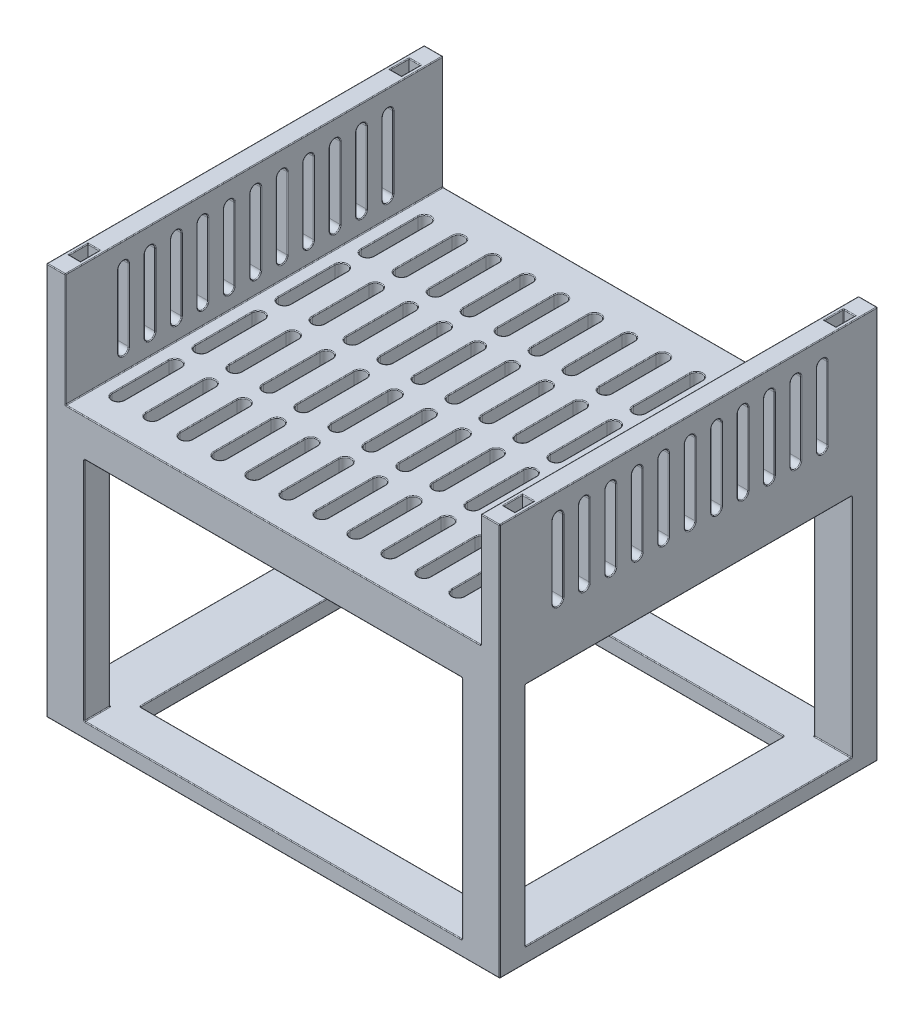
from build123d import *

# Parameters (mm, degrees)
ESBO_O1_W                 = 600
ESBO_O1_H                 = 500
RESSALTO_EXTRUS_O1_DEPTH  = 50
ESBO_O3_W                 = 25
ESBO_O3_H                 = 500
RESSALTO_EXTRUS_O2_DEPTH  = 150
CORTE_EXTRUS_O6_DEPTH     = 201
PADR_O_LINEAR1_COUNT      = 12
PADR_O_LINEAR1_PITCH      = 45
PADR_O_LINEAR1_COUNT_DIR2 = 4
PADR_O_LINEAR1_PITCH_DIR2 = 110
ESBO_O15_W                = 50
ESBO_O15_H                = 34
RESSALTO_EXTRUS_O4_DEPTH  = 300
ESBO_O16_W                = 600
ESBO_O16_H                = 500
ESBO_O16_W_2              = 460
ESBO_O16_H_2              = 392
RESSALTO_EXTRUS_O6_DEPTH  = 20
ESBO_O17_W                = 15
ESBO_O17_H                = 25
CORTE_EXTRUS_O7_DEPTH     = 60
CORTE_EXTRUS_O8_DEPTH     = 601
PADR_O_LINEAR2_COUNT      = 11
PADR_O_LINEAR2_PITCH      = 35
FILETE1_R                 = 1


with BuildPart() as part:
    # Esboço1 → Ressalto-extrusão1 (new body)
    with BuildSketch(Plane(origin=(0, 0, 0), x_dir=(1, 0, 0), z_dir=(0, 1, 0))):
        with Locations((300, 250)):
            Rectangle(ESBO_O1_W, ESBO_O1_H)
    extrude(amount=RESSALTO_EXTRUS_O1_DEPTH)

    # Esboço3 → Ressalto-extrusão2 (add)
    with BuildSketch(Plane(origin=(0, 50, 0), x_dir=(1, 0, 0), z_dir=(0, 1, 0))):
        with Locations((12.5, 250)):
            Rectangle(ESBO_O3_W, ESBO_O3_H)
        with Locations((587.5, 250)):
            Rectangle(ESBO_O3_W, ESBO_O3_H)
    extrude(amount=RESSALTO_EXTRUS_O2_DEPTH)

    # Esboço13 → Corte-extrusão6 (cut, through all)
    with BuildSketch(Plane.XZ):
        with BuildLine():
            Line((58, -45), (58, -120))
            ThreePointArc((58, -120), (50, -128), (42, -120))
            Line((42, -120), (42, -45))
            ThreePointArc((42, -45), (50, -37), (58, -45))
        make_face()
    corte_extrus_o6 = extrude(amount=-CORTE_EXTRUS_O6_DEPTH, mode=Mode.SUBTRACT)

    # Padrão linear1: Corte-extrus_o6 12 × 4
    with Locations(*[(i * PADR_O_LINEAR1_PITCH, 0, -j * PADR_O_LINEAR1_PITCH_DIR2) for i in range(PADR_O_LINEAR1_COUNT) for j in range(PADR_O_LINEAR1_COUNT_DIR2) if (i, j) != (0, 0)]):
        add(corte_extrus_o6, mode=Mode.SUBTRACT)

    # Esboço15 → Ressalto-extrusão4 (add)
    with BuildSketch(Plane.XZ):
        with Locations((25, -17)):
            Rectangle(ESBO_O15_W, ESBO_O15_H)
        with Locations((575, -17)):
            Rectangle(ESBO_O15_W, ESBO_O15_H)
        with Locations((575, -483)):
            Rectangle(ESBO_O15_W, ESBO_O15_H)
        with Locations((25, -483)):
            Rectangle(ESBO_O15_W, ESBO_O15_H)
    extrude(amount=RESSALTO_EXTRUS_O4_DEPTH)

    # Esboço16 → Ressalto-extrusão6 (add)
    with BuildSketch(Plane.XZ.offset(300)):
        with Locations((300, -250)):
            Rectangle(ESBO_O16_W, ESBO_O16_H)
        with Locations((300, -250)):
            Rectangle(ESBO_O16_W_2, ESBO_O16_H_2, mode=Mode.SUBTRACT)
    extrude(amount=RESSALTO_EXTRUS_O6_DEPTH)

    # Esboço17 → Corte-extrusão7 (cut)
    with BuildSketch(Plane(origin=(0, 200, 0), x_dir=(1, 0, 0), z_dir=(0, 1, 0))):
        with Locations((12.5, 462.5)):
            Rectangle(ESBO_O17_W, ESBO_O17_H)
        with Locations((587.5, 462.5)):
            Rectangle(ESBO_O17_W, ESBO_O17_H)
        with Locations((587.5, 37.5)):
            Rectangle(ESBO_O17_W, ESBO_O17_H)
        with Locations((12.5, 37.5)):
            Rectangle(ESBO_O17_W, ESBO_O17_H)
    extrude(amount=-CORTE_EXTRUS_O7_DEPTH, mode=Mode.SUBTRACT)

    # Esboço18 → Corte-extrusão8 (cut, through all)
    with BuildSketch(Plane(origin=(600, 0, 0), x_dir=(0, 0, -1), z_dir=(1, 0, 0))):
        with BuildLine():
            Line((84, 170), (84, 75))
            ThreePointArc((84, 75), (77, 68), (70, 75))
            Line((70, 75), (70, 170))
            ThreePointArc((70, 170), (77, 177), (84, 170))
        make_face()
    corte_extrus_o8 = extrude(amount=-CORTE_EXTRUS_O8_DEPTH, mode=Mode.SUBTRACT)

    # Padrão linear2: Corte-extrusão8 ×11
    with Locations(*[(0, 0, -i * PADR_O_LINEAR2_PITCH) for i in range(1, PADR_O_LINEAR2_COUNT)]):
        add(corte_extrus_o8, mode=Mode.SUBTRACT)

    # Filete1
    filete1_edges = [part.edges().sort_by_distance(p)[0] for p in [
        (320, 0, -37),
        (328, 0, -82.5),
        (320, 0, -128),
        (312, 0, -82.5),
        (320, 50, -37),
        (312, 50, -82.5),
        (320, 50, -128),
        (328, 50, -82.5),
        (365, 0, -37),
        (373, 0, -82.5),
        (365, 0, -128),
        (357, 0, -82.5),
        (365, 50, -37),
        (357, 50, -82.5),
        (365, 50, -128),
        (373, 50, -82.5),
        (410, 0, -37),
        (418, 0, -82.5),
        (410, 0, -128),
        (402, 0, -82.5),
        (410, 50, -37),
        (402, 50, -82.5),
        (410, 50, -128),
        (418, 50, -82.5),
        (455, 0, -37),
        (463, 0, -82.5),
        (455, 0, -128),
        (447, 0, -82.5),
        (455, 50, -37),
        (447, 50, -82.5),
        (455, 50, -128),
        (463, 50, -82.5),
        (500, 0, -37),
        (508, 0, -82.5),
        (300, 50, 0),
        (500, 0, -128),
        (492, 0, -82.5),
        (500, 50, -37),
        (492, 50, -82.5),
        (500, 50, -128),
        (508, 50, -82.5),
        (545, 0, -37),
        (553, 0, -82.5),
        (545, 0, -128),
        (537, 0, -82.5),
        (545, 50, -37),
        (537, 50, -82.5),
        (545, 50, -128),
        (553, 50, -82.5),
        (50, 0, -147),
        (58, 0, -192.5),
        (50, 0, -238),
        (42, 0, -192.5),
        (50, 50, -147),
        (42, 50, -192.5),
        (50, 50, -238),
        (58, 50, -192.5),
        (25, 50, -250),
        (25, 125, 0),
        (95, 0, -147),
        (103, 0, -192.5),
        (95, 0, -238),
        (87, 0, -192.5),
        (95, 50, -147),
        (87, 50, -192.5),
        (25, 125, -500),
        (95, 50, -238),
        (103, 50, -192.5),
        (0, 200, -250),
        (12.5, 200, 0),
        (140, 0, -147),
        (148, 0, -192.5),
        (140, 0, -238),
        (25, 200, -250),
        (132, 0, -192.5),
        (140, 50, -147),
        (132, 50, -192.5),
        (140, 50, -238),
        (148, 50, -192.5),
        (12.5, 200, -500),
        (185, 0, -147),
        (193, 0, -192.5),
        (185, 0, -238),
        (177, 0, -192.5),
        (185, 50, -147),
        (177, 50, -192.5),
        (185, 50, -238),
        (193, 50, -192.5),
        (230, 0, -147),
        (238, 0, -192.5),
        (230, 0, -238),
        (222, 0, -192.5),
        (230, 50, -147),
        (222, 50, -192.5),
        (230, 50, -238),
        (238, 50, -192.5),
        (275, 0, -147),
        (283, 0, -192.5),
        (275, 0, -238),
        (267, 0, -192.5),
        (275, 50, -147),
        (267, 50, -192.5),
        (275, 50, -238),
        (283, 50, -192.5),
        (320, 0, -147),
        (328, 0, -192.5),
        (320, 0, -238),
        (312, 0, -192.5),
        (320, 50, -147),
        (312, 50, -192.5),
        (320, 50, -238),
        (328, 50, -192.5),
        (365, 0, -147),
        (373, 0, -192.5),
        (365, 0, -238),
        (357, 0, -192.5),
        (365, 50, -147),
        (357, 50, -192.5),
        (365, 50, -238),
        (373, 50, -192.5),
        (410, 0, -147),
        (418, 0, -192.5),
        (410, 0, -238),
        (402, 0, -192.5),
        (410, 50, -147),
        (402, 50, -192.5),
        (410, 50, -238),
        (418, 50, -192.5),
        (455, 0, -147),
        (463, 0, -192.5),
        (455, 0, -238),
        (447, 0, -192.5),
        (455, 50, -147),
        (447, 50, -192.5),
        (455, 50, -238),
        (463, 50, -192.5),
        (500, 0, -147),
        (508, 0, -192.5),
        (500, 0, -238),
        (492, 0, -192.5),
        (500, 50, -147),
        (492, 50, -192.5),
        (500, 50, -238),
        (508, 50, -192.5),
        (545, 0, -147),
        (553, 0, -192.5),
        (545, 0, -238),
        (537, 0, -192.5),
        (545, 50, -147),
        (537, 50, -192.5),
        (545, 50, -238),
        (553, 50, -192.5),
        (300, 50, -500),
        (50, 0, -257),
        (58, 0, -302.5),
        (50, 0, -348),
        (42, 0, -302.5),
        (50, 50, -257),
        (42, 50, -302.5),
        (50, 50, -348),
        (58, 50, -302.5),
        (95, 0, -257),
        (103, 0, -302.5),
        (95, 0, -348),
        (87, 0, -302.5),
        (95, 50, -257),
        (87, 50, -302.5),
        (95, 50, -348),
        (103, 50, -302.5),
        (575, 50, -250),
        (140, 0, -257),
        (148, 0, -302.5),
        (140, 0, -348),
        (132, 0, -302.5),
        (575, 125, -500),
        (140, 50, -257),
        (132, 50, -302.5),
        (140, 50, -348),
        (148, 50, -302.5),
        (575, 125, 0),
        (600, 200, -250),
        (185, 0, -257),
        (193, 0, -302.5),
        (185, 0, -348),
        (177, 0, -302.5),
        (587.5, 200, -500),
        (185, 50, -257),
        (177, 50, -302.5),
        (185, 50, -348),
        (193, 50, -302.5),
        (575, 200, -250),
        (587.5, 200, 0),
        (230, 0, -257),
        (238, 0, -302.5),
        (230, 0, -348),
        (222, 0, -302.5),
        (230, 50, -257),
        (222, 50, -302.5),
        (230, 50, -348),
        (238, 50, -302.5),
        (275, 0, -257),
        (283, 0, -302.5),
        (275, 0, -348),
        (267, 0, -302.5),
        (275, 50, -257),
        (267, 50, -302.5),
        (275, 50, -348),
        (283, 50, -302.5),
        (320, 0, -257),
        (328, 0, -302.5),
        (320, 0, -348),
        (312, 0, -302.5),
        (320, 50, -257),
        (312, 50, -302.5),
        (320, 50, -348),
        (328, 50, -302.5),
        (365, 0, -257),
        (373, 0, -302.5),
        (365, 0, -348),
        (357, 0, -302.5),
        (365, 50, -257),
        (357, 50, -302.5),
        (365, 50, -348),
        (373, 50, -302.5),
        (410, 0, -257),
        (418, 0, -302.5),
        (410, 0, -348),
        (402, 0, -302.5),
        (410, 50, -257),
        (402, 50, -302.5),
        (410, 50, -348),
        (418, 50, -302.5),
        (455, 0, -257),
        (463, 0, -302.5),
        (455, 0, -348),
        (447, 0, -302.5),
        (455, 50, -257),
        (447, 50, -302.5),
        (455, 50, -348),
        (463, 50, -302.5),
        (500, 0, -257),
        (508, 0, -302.5),
        (500, 0, -348),
        (492, 0, -302.5),
        (500, 50, -257),
        (492, 50, -302.5),
        (500, 50, -348),
        (508, 50, -302.5),
        (545, 0, -257),
        (553, 0, -302.5),
        (545, 0, -348),
        (537, 0, -302.5),
        (545, 50, -257),
        (537, 50, -302.5),
        (545, 50, -348),
        (553, 50, -302.5),
        (50, 0, -367),
        (58, 0, -412.5),
        (50, 0, -458),
        (42, 0, -412.5),
        (50, 50, -367),
        (42, 50, -412.5),
        (50, 50, -458),
        (58, 50, -412.5),
        (95, 0, -367),
        (103, 0, -412.5),
        (95, 0, -458),
        (87, 0, -412.5),
        (95, 50, -367),
        (87, 50, -412.5),
        (95, 50, -458),
        (103, 50, -412.5),
        (140, 0, -367),
        (148, 0, -412.5),
        (140, 0, -458),
        (132, 0, -412.5),
        (140, 50, -367),
        (132, 50, -412.5),
        (140, 50, -458),
        (148, 50, -412.5),
        (185, 0, -367),
        (193, 0, -412.5),
        (185, 0, -458),
        (177, 0, -412.5),
        (185, 50, -367),
        (177, 50, -412.5),
        (185, 50, -458),
        (193, 50, -412.5),
        (230, 0, -367),
        (238, 0, -412.5),
        (230, 0, -458),
        (222, 0, -412.5),
        (230, 50, -367),
        (222, 50, -412.5),
        (230, 50, -458),
        (238, 50, -412.5),
        (275, 0, -367),
        (283, 0, -412.5),
        (275, 0, -458),
        (267, 0, -412.5),
        (275, 50, -367),
        (267, 50, -412.5),
        (275, 50, -458),
        (283, 50, -412.5),
        (320, 0, -367),
        (328, 0, -412.5),
        (320, 0, -458),
        (312, 0, -412.5),
        (320, 50, -367),
        (312, 50, -412.5),
        (320, 50, -458),
        (328, 50, -412.5),
        (365, 0, -367),
        (373, 0, -412.5),
        (365, 0, -458),
        (357, 0, -412.5),
        (365, 50, -367),
        (357, 50, -412.5),
        (365, 50, -458),
        (373, 50, -412.5),
        (410, 0, -367),
        (418, 0, -412.5),
        (410, 0, -458),
        (402, 0, -412.5),
        (410, 50, -367),
        (402, 50, -412.5),
        (410, 50, -458),
        (418, 50, -412.5),
        (50, 50, -37),
        (58, 50, -82.5),
        (455, 0, -367),
        (463, 0, -412.5),
        (455, 0, -458),
        (447, 0, -412.5),
        (455, 50, -367),
        (447, 50, -412.5),
        (455, 50, -458),
        (50, 50, -128),
        (463, 50, -412.5),
        (42, 50, -82.5),
        (500, 0, -367),
        (508, 0, -412.5),
        (500, 0, -458),
        (492, 0, -412.5),
        (500, 50, -367),
        (492, 50, -412.5),
        (500, 50, -458),
        (508, 50, -412.5),
        (545, 0, -367),
        (553, 0, -412.5),
        (545, 0, -458),
        (537, 0, -412.5),
        (545, 50, -367),
        (537, 50, -412.5),
        (545, 50, -458),
        (553, 50, -412.5),
        (50, 0, -37),
        (42, 0, -82.5),
        (50, 0, -128),
        (58, 0, -82.5),
        (300, 0, 0),
        (25, 0, -34),
        (0, -150, -34),
        (50, 0, -17),
        (50, -150, -34),
        (50, -150, 0),
        (25, -300, -34),
        (50, -300, -17),
        (600, 0, -250),
        (550, 0, -17),
        (550, -150, 0),
        (575, 0, -34),
        (550, -150, -34),
        (600, -150, -34),
        (550, -300, -17),
        (575, -300, -34),
        (300, 0, -500),
        (575, 0, -466),
        (600, -150, -466),
        (550, 0, -483),
        (550, -150, -466),
        (550, -150, -500),
        (575, -300, -466),
        (550, -300, -483),
        (0, 0, -250),
        (50, 0, -483),
        (50, -150, -500),
        (25, 0, -466),
        (50, -150, -466),
        (0, -150, -466),
        (50, -300, -483),
        (25, -300, -466),
        (300, -300, -54),
        (70, -300, -250),
        (300, -300, -446),
        (0, -300, -250),
        (600, -300, -250),
        (300, -320, -54),
        (70, -310, -54),
        (530, -300, -250),
        (530, -310, -54),
        (300, -320, -446),
        (530, -310, -446),
        (300, -300, 0),
        (0, -320, -250),
        (300, -300, -500),
        (600, -320, -250),
        (70, -320, -250),
        (70, -310, -446),
        (300, -320, 0),
        (300, -320, -500),
        (530, -320, -250),
        (95, 0, -37),
        (12.5, 200, -25),
        (20, 200, -37.5),
        (87, 0, -82.5),
        (12.5, 200, -50),
        (5, 200, -37.5),
        (95, 0, -128),
        (103, 0, -82.5),
        (580, 170, -475),
        (587.5, 200, -475),
        (580, 200, -462.5),
        (95, 50, -37),
        (587.5, 200, -450),
        (595, 200, -462.5),
        (103, 50, -82.5),
        (595, 200, -37.5),
        (587.5, 200, -50),
        (580, 200, -37.5),
        (95, 50, -128),
        (587.5, 200, -25),
        (87, 50, -82.5),
        (5, 200, -462.5),
        (12.5, 200, -450),
        (20, 200, -462.5),
        (12.5, 200, -475),
        (575, 122.5, -70),
        (575, 68, -77),
        (575, 122.5, -84),
        (575, 177, -77),
        (25, 177, -77),
        (0, 177, -77),
        (25, 122.5, -84),
        (0, 122.5, -84),
        (25, 68, -77),
        (0, 68, -77),
        (25, 122.5, -70),
        (0, 122.5, -70),
        (600, 177, -77),
        (600, 122.5, -70),
        (600, 68, -77),
        (600, 122.5, -84),
        (140, 0, -37),
        (148, 0, -82.5),
        (140, 0, -128),
        (132, 0, -82.5),
        (25, 177, -112),
        (0, 177, -112),
        (25, 122.5, -119),
        (0, 122.5, -119),
        (25, 68, -112),
        (0, 68, -112),
        (25, 122.5, -105),
        (0, 122.5, -105),
        (140, 50, -37),
        (132, 50, -82.5),
        (140, 50, -128),
        (0, 177, -147),
        (0, 122.5, -140),
        (0, 68, -147),
        (0, 122.5, -154),
        (25, 177, -147),
        (25, 122.5, -154),
        (25, 68, -147),
        (25, 122.5, -140),
        (148, 50, -82.5),
        (0, 177, -182),
        (0, 122.5, -175),
        (0, 68, -182),
        (0, 122.5, -189),
        (25, 177, -182),
        (25, 122.5, -189),
        (25, 68, -182),
        (25, 122.5, -175),
        (0, 177, -217),
        (0, 122.5, -210),
        (0, 68, -217),
        (0, 122.5, -224),
        (25, 177, -217),
        (25, 122.5, -224),
        (25, 68, -217),
        (25, 122.5, -210),
        (0, 177, -252),
        (0, 122.5, -245),
        (0, 68, -252),
        (0, 122.5, -259),
        (25, 177, -252),
        (25, 122.5, -259),
        (25, 68, -252),
        (25, 122.5, -245),
        (0, -60, -500),
        (0, 177, -287),
        (0, 122.5, -280),
        (0, 68, -287),
        (0, 122.5, -294),
        (25, 177, -287),
        (25, 122.5, -294),
        (25, 68, -287),
        (25, 122.5, -280),
        (600, -60, -500),
        (0, 177, -322),
        (0, 122.5, -315),
        (0, 68, -322),
        (0, 122.5, -329),
        (25, 177, -322),
        (25, 122.5, -329),
        (25, 68, -322),
        (25, 122.5, -315),
        (0, 177, -357),
        (0, 122.5, -350),
        (0, 68, -357),
        (0, 122.5, -364),
        (25, 177, -357),
        (600, -60, 0),
        (25, 122.5, -364),
        (25, 68, -357),
        (25, 122.5, -350),
        (0, 177, -392),
        (0, 122.5, -385),
        (0, 68, -392),
        (0, 122.5, -399),
        (25, 177, -392),
        (25, 122.5, -399),
        (25, 68, -392),
        (25, 122.5, -385),
        (0, -60, 0),
        (185, 0, -37),
        (0, 177, -427),
        (0, 122.5, -420),
        (193, 0, -82.5),
        (0, 68, -427),
        (0, 122.5, -434),
        (25, 177, -427),
        (25, 122.5, -434),
        (25, 68, -427),
        (25, 122.5, -420),
        (185, 0, -128),
        (177, 0, -82.5),
        (185, 50, -37),
        (177, 50, -82.5),
        (185, 50, -128),
        (193, 50, -82.5),
        (600, 122.5, -105),
        (600, 68, -112),
        (600, 122.5, -119),
        (600, 177, -112),
        (575, 122.5, -105),
        (575, 68, -112),
        (575, 122.5, -119),
        (575, 177, -112),
        (600, 122.5, -140),
        (600, 177, -147),
        (600, 122.5, -154),
        (600, 68, -147),
        (575, 122.5, -140),
        (575, 68, -147),
        (575, 122.5, -154),
        (575, 177, -147),
        (600, 122.5, -175),
        (600, 177, -182),
        (600, 122.5, -189),
        (600, 68, -182),
        (575, 122.5, -175),
        (575, 68, -182),
        (575, 122.5, -189),
        (575, 177, -182),
        (600, 122.5, -210),
        (600, 177, -217),
        (600, 122.5, -224),
        (600, 68, -217),
        (575, 122.5, -210),
        (575, 68, -217),
        (575, 122.5, -224),
        (575, 177, -217),
        (600, 122.5, -245),
        (600, 177, -252),
        (600, 122.5, -259),
        (600, 68, -252),
        (575, 122.5, -245),
        (575, 68, -252),
        (575, 122.5, -259),
        (575, 177, -252),
        (600, 122.5, -280),
        (600, 177, -287),
        (600, 122.5, -294),
        (600, 68, -287),
        (575, 122.5, -280),
        (575, 68, -287),
        (575, 122.5, -294),
        (575, 177, -287),
        (600, 122.5, -315),
        (600, 177, -322),
        (600, 122.5, -329),
        (600, 68, -322),
        (575, 122.5, -315),
        (575, 68, -322),
        (575, 122.5, -329),
        (575, 177, -322),
        (600, 122.5, -350),
        (600, 177, -357),
        (600, 122.5, -364),
        (230, 0, -37),
        (600, 68, -357),
        (575, 122.5, -350),
        (575, 68, -357),
        (575, 122.5, -364),
        (575, 177, -357),
        (238, 0, -82.5),
        (230, 0, -128),
        (600, 122.5, -385),
        (600, 177, -392),
        (600, 122.5, -399),
        (600, 68, -392),
        (575, 122.5, -385),
        (575, 68, -392),
        (575, 122.5, -399),
        (222, 0, -82.5),
        (575, 177, -392),
        (230, 50, -37),
        (222, 50, -82.5),
        (600, 122.5, -420),
        (600, 177, -427),
        (600, 122.5, -434),
        (600, 68, -427),
        (575, 122.5, -420),
        (575, 68, -427),
        (575, 122.5, -434),
        (575, 177, -427),
        (230, 50, -128),
        (238, 50, -82.5),
        (275, 0, -37),
        (283, 0, -82.5),
        (275, 0, -128),
        (267, 0, -82.5),
        (275, 50, -37),
        (267, 50, -82.5),
        (275, 50, -128),
        (283, 50, -82.5),
    ]]
    fillet(filete1_edges, radius=FILETE1_R)


solid = part.part
